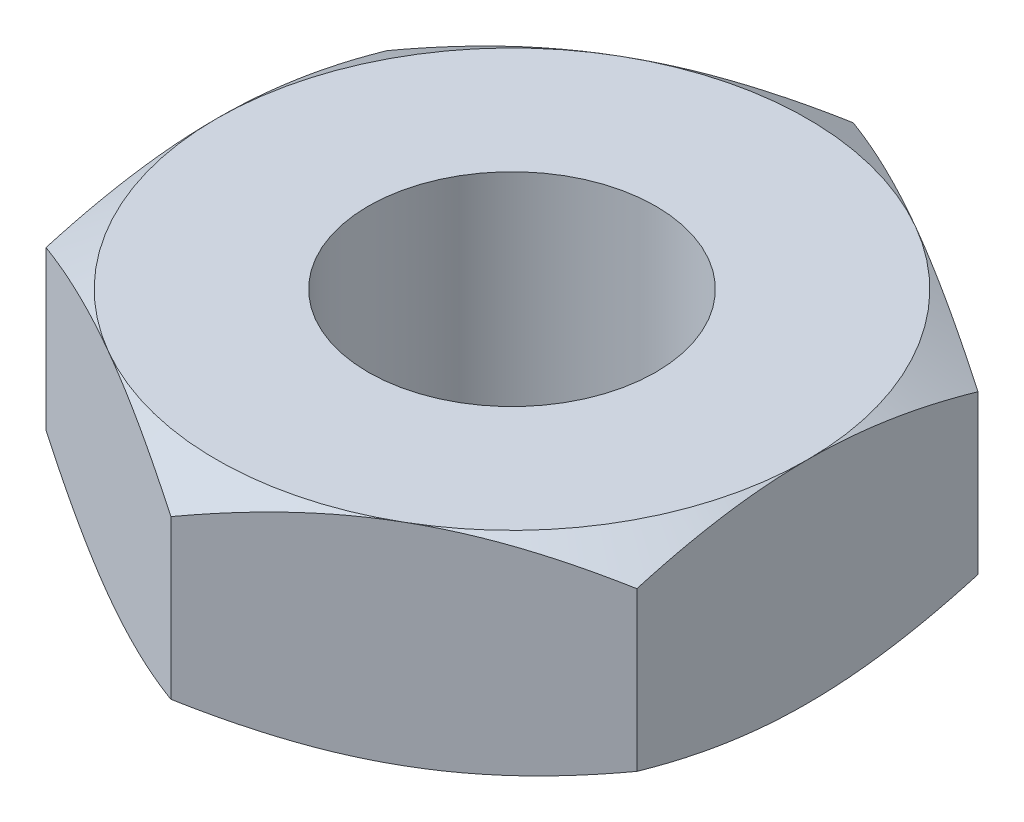
from build123d import *

# Parameters (mm, degrees)
BOSS_EXTRUDE1_DEPTH     = 1.984375
F_1_4_28_TAPPED_HOLE1_D = 5.4102
SKETCH5_OUTSIDE_W       = 33.81
SKETCH5_OUTSIDE_H       = 35.53
SKETCH5_OUTSIDE_R       = 5.55625
CUT_EXTRUDE2_DEPTH      = 4.96875
CUT_EXTRUDE2_TAPER      = 60


with BuildPart() as part:
    # Sketch1 → Boss-Extrude1 (new body, symmetric)
    with BuildSketch(Plane(origin=(0, 0, 0), x_dir=(1, 0, 0), z_dir=(0, 1, 0))):
        Polygon((-5.55625, 3.207902433), (-5.55625, -3.207902433), (0, -6.415804866), (5.55625, -3.207902433), (5.55625, 3.207902433), (0, 6.415804866), align=None)
    extrude(amount=BOSS_EXTRUDE1_DEPTH, both=True)

    # 1/4-28 Tapped Hole1 (through all)
    with Locations(Plane(origin=(0, 1.984375, 0), x_dir=(1, 0, 0), z_dir=(0, 1, 0))):
        with Locations((0, 0)):
            Hole(F_1_4_28_TAPPED_HOLE1_D / 2)

    # Sketch5 outside → Cut-Extrude2 (cut, through all)
    with BuildSketch(Plane(origin=(0, 1.984375, 0), x_dir=(1, 0, 0), z_dir=(0, 1, 0))):
        Rectangle(SKETCH5_OUTSIDE_W, SKETCH5_OUTSIDE_H)
        Circle(SKETCH5_OUTSIDE_R, mode=Mode.SUBTRACT)
    cut_extrude2 = extrude(amount=-CUT_EXTRUDE2_DEPTH, taper=CUT_EXTRUDE2_TAPER, mode=Mode.SUBTRACT)

    # Mirror1: Cut-Extrude2 across plane
    add(cut_extrude2.mirror(Plane.ZX), mode=Mode.SUBTRACT)


solid = part.part
